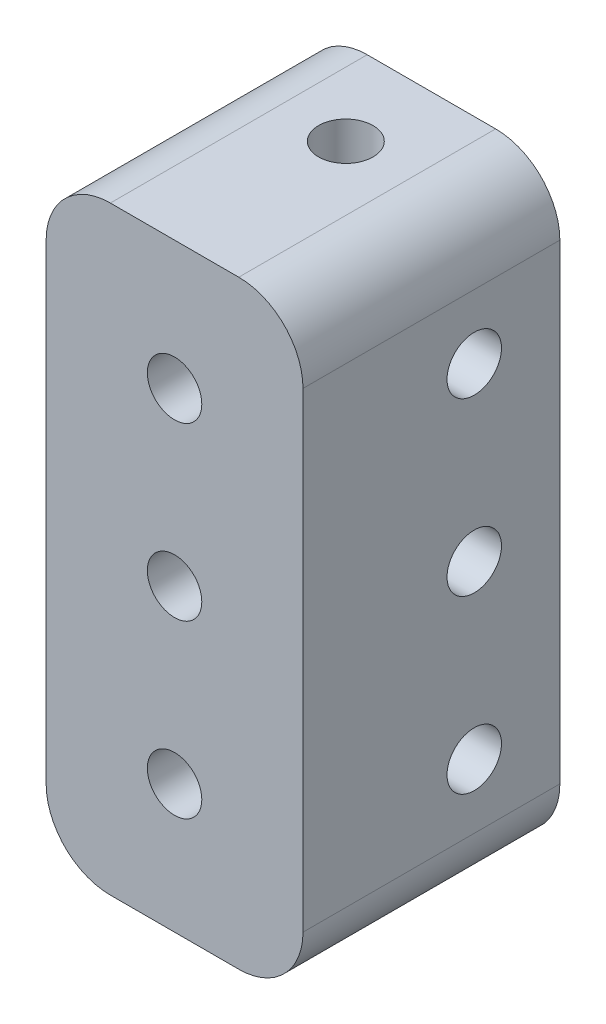
from build123d import *

# Parameters (mm, degrees)
SKETCH3_W                       = 19.05
SKETCH3_H                       = 44.45
BOSS_EXTRUDE1_DEPTH             = 457.2
BOSS_EXTRUDE1_DEPTH_BACK        = 457.2
FILLET1_R                       = 4.7625
SKETCH4_W                       = 447.675
SKETCH4_H                       = 44.45
CUT_EXTRUDE1_DEPTH              = 20.05
F_10_32_TAPPED_HOLE1_AT_2_COUNT = 2
F_10_32_TAPPED_HOLE1_AT_2_PITCH = 12.7
F_10_32_TAPPED_HOLE1_AT_3_COUNT = 2
F_10_32_TAPPED_HOLE1_AT_3_PITCH = 25.4
F_10_32_TAPPED_HOLE2_D          = 4.0386
F_10_32_TAPPED_HOLE2_DEPTH      = 9.525
F_10_32_TAPPED_HOLE2_TIP        = 1.213317848


with BuildPart() as part:
    # Sketch3 → Boss-Extrude1 (new body, two sides)
    with BuildSketch(Plane.XY) as boss_extrude1_sk:
        Rectangle(SKETCH3_W, SKETCH3_H)
    extrude(amount=BOSS_EXTRUDE1_DEPTH)
    extrude(boss_extrude1_sk.sketch, amount=-BOSS_EXTRUDE1_DEPTH_BACK)

    # Fillet1
    fillet1_edges = [part.edges().sort_by_distance(p)[0] for p in [
        (9.525, -22.225, 0),
        (-9.525, -22.225, 0),
        (-9.525, 22.225, 0),
        (9.525, 22.225, 0),
    ]]
    fillet(fillet1_edges, radius=FILLET1_R)

    # Sketch4 → Cut-Extrude1 (cut, through all)
    with BuildSketch(Plane(origin=(9.525, 0, 0), x_dir=(0, 0, -1), z_dir=(1, 0, 0))):
        with Locations((-233.3625, 0)):
            Rectangle(SKETCH4_W, SKETCH4_H)
        with Locations((233.3625, 0)):
            Rectangle(SKETCH4_W, SKETCH4_H)
    extrude(amount=-CUT_EXTRUDE1_DEPTH, mode=Mode.SUBTRACT)

    # Sketch6 → #10-32 Tapped Hole1 (revolve, cut)
    with BuildSketch(Plane(origin=(9.525, 12.7, -3.175), x_dir=(0, 0, -1), z_dir=(0, 1, 0))):
        Polygon((0, 0), (0, 10.738317848), (2.0193, 9.525), (2.0193, 0), align=None)
    f_10_32_tapped_hole1 = revolve(axis=Axis((15.875, 12.7, -3.175), (-1, 0, 0)), mode=Mode.SUBTRACT)

    # #10-32 Tapped Hole1 at 2: #10-32 Tapped Hole1 ×2
    with Locations(*[(0, -i * F_10_32_TAPPED_HOLE1_AT_2_PITCH, 0) for i in range(1, F_10_32_TAPPED_HOLE1_AT_2_COUNT)]):
        add(f_10_32_tapped_hole1, mode=Mode.SUBTRACT)

    # #10-32 Tapped Hole1 at 3: #10-32 Tapped Hole1 ×2
    with Locations(*[(0, -i * F_10_32_TAPPED_HOLE1_AT_3_PITCH, 0) for i in range(1, F_10_32_TAPPED_HOLE1_AT_3_COUNT)]):
        add(f_10_32_tapped_hole1, mode=Mode.SUBTRACT)

    # #10-32 Tapped Hole2
    with Locations(Plane.XY.offset(9.525)):
        with Locations((0, 0), (0, 12.7), (0, -12.7)):
            Hole(F_10_32_TAPPED_HOLE2_D / 2, depth=F_10_32_TAPPED_HOLE2_DEPTH)
            with Locations((0, 0, -(F_10_32_TAPPED_HOLE2_DEPTH + F_10_32_TAPPED_HOLE2_TIP / 2))):  # 118° drill point
                Cone(0, F_10_32_TAPPED_HOLE2_D / 2, F_10_32_TAPPED_HOLE2_TIP, mode=Mode.SUBTRACT)

    # Sketch12 → #10-32 Tapped Hole3 (revolve, cut)
    with BuildSketch(Plane(origin=(0, 22.225, -3.175), x_dir=(0, 0, 1), z_dir=(1, 0, 0))):
        Polygon((0, 0), (0, 10.738317848), (2.0193, 9.525), (2.0193, 0), align=None)
    f_10_32_tapped_hole3 = revolve(axis=Axis((0, 28.575, -3.175), (0, -1, 0)), mode=Mode.SUBTRACT)

    # Mirror1: #10-32 Tapped Hole3 across plane
    add(f_10_32_tapped_hole3.mirror(Plane.ZX), mode=Mode.SUBTRACT)

    # Mirror2: #10-32 Tapped Hole1 across plane
    add(f_10_32_tapped_hole1.mirror(Plane(origin=(0, 0, 0), x_dir=(0, 0, 1), z_dir=(1, 0, 0))), mode=Mode.SUBTRACT)

    # Mirror2 copy 1 sketch → Mirror2 copy 1 (revolve, cut)
    with BuildSketch(Plane(origin=(-9.525, 0, -3.175), x_dir=(0, 0, -1), z_dir=(0, 1, 0))):
        Polygon((0, 0), (0, -10.738317848), (2.0193, -9.525), (2.0193, 0), align=None)
    revolve(axis=Axis((-15.875, 0, -3.175), (-1, 0, 0)), mode=Mode.SUBTRACT)

    # Mirror2 copy 2 sketch → Mirror2 copy 2 (revolve, cut)
    with BuildSketch(Plane(origin=(-9.525, -12.7, -3.175), x_dir=(0, 0, -1), z_dir=(0, 1, 0))):
        Polygon((0, 0), (0, -10.738317848), (2.0193, -9.525), (2.0193, 0), align=None)
    revolve(axis=Axis((-15.875, -12.7, -3.175), (-1, 0, 0)), mode=Mode.SUBTRACT)


solid = part.part
